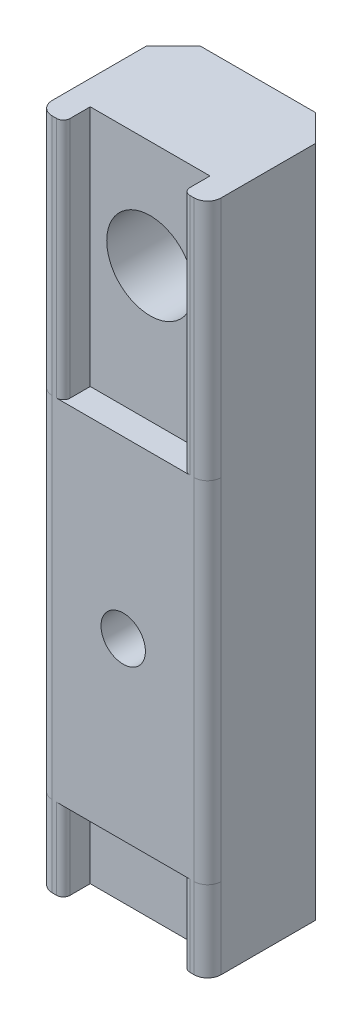
from build123d import *

# Parameters (mm, degrees)
BOSS_EXTRUDE1_DEPTH = 50
CUT_EXTRUDE2_DEPTH  = 53.511927217
FILLET1_R           = 0.5
SKETCH4_R           = 3.225
SKETCH4_R_2         = 1.65
CUT_EXTRUDE3_DEPTH  = 53.511927217
BOSS_EXTRUDE2_REACH = 54.024
SKETCH5_W           = 12.55
SKETCH5_H           = 26
SKETCH5_R           = 1.65
FILLET2_R           = 1
CUT_EXTRUDE4_DEPTH  = 4
BOSS_EXTRUDE3_DEPTH = 18
SKETCH8_R           = 3.225
CUT_EXTRUDE5_DEPTH  = 53.024056935
BOSS_EXTRUDE4_DEPTH = 6


with BuildPart() as part:
    # Sketch1 → Boss-Extrude1 (new body)
    with BuildSketch(Plane(origin=(0, 0, 0), x_dir=(1, 0, 0), z_dir=(0, 1, 0))):
        with BuildLine():
            Line((0, 8), (2, 10))
            Line((2, 10), (10.55, 10))
            Line((10.55, 10), (12.55, 8))
            Line((12.55, 8), (12.55, 1))
            ThreePointArc((12.55, 1), (12.257106781, 0.292893219), (11.55, 0))
            Line((11.55, 0), (1, 0))
            ThreePointArc((1, 0), (0.292893219, 0.292893219), (0, 1))
            Line((0, 1), (0, 8))
        make_face()
    extrude(amount=BOSS_EXTRUDE1_DEPTH)

    # Sketch3 → Cut-Extrude2 (cut, through all)
    with BuildSketch(Plane.XZ):
        Polygon((1.825, 0), (1.825, -2), (2.825, -3), (9.725, -3), (10.725, -2), (10.725, 0), align=None)
    extrude(amount=-CUT_EXTRUDE2_DEPTH, mode=Mode.SUBTRACT)

    # Fillet1
    fillet1_edges = [part.edges().sort_by_distance(p)[0] for p in [
        (1.825, 25, 0),
        (10.725, 25, 0),
    ]]
    fillet(fillet1_edges, radius=FILLET1_R)

    # Sketch4 → Cut-Extrude3 (cut, through all)
    with BuildSketch(Plane(origin=(0, 0, -10), x_dir=(-1, 0, 0), z_dir=(0, 0, -1))):
        with Locations((-6.275, 42)):
            Circle(SKETCH4_R)
        with Locations((-6.275, 19)):
            Circle(SKETCH4_R_2)
    extrude(amount=-CUT_EXTRUDE3_DEPTH, mode=Mode.SUBTRACT)

    # Boss-Extrude2: up to this face of the body (flat: up to its plane)
    boss_extrude2_end = Plane(part.part.faces().sort_by_distance((1.1625, 25, 0))[0])
    # Sketch5 → Boss-Extrude2 (add, up to the picked face)
    with BuildSketch(Plane.XY.offset(-3), mode=Mode.PRIVATE) as boss_extrude2_sk1:
        with Locations((6.275, 19)):
            Rectangle(SKETCH5_W, SKETCH5_H)
        with Locations(Location((6.275, 19, 0), (0, 0, 180))):
            Circle(SKETCH5_R, mode=Mode.SUBTRACT)
    boss_extrude2_tool1 = split(extrude(boss_extrude2_sk1.sketch, amount=BOSS_EXTRUDE2_REACH, mode=Mode.PRIVATE), bisect_by=boss_extrude2_end, keep=Keep.BOTH, mode=Mode.PRIVATE)
    add(boss_extrude2_tool1.solids().sort_by(Axis((6.275, 6.288704, -3), (0, 0, 1)))[0])

    # Fillet2
    fillet2_edges = [part.edges().sort_by_distance(p)[0] for p in [
        (12.55, 19, 0),
        (0, 19, 0),
    ]]
    fillet(fillet2_edges, radius=FILLET2_R)

    # Sketch6 → Cut-Extrude4 (cut)
    with BuildSketch(Plane(origin=(0, 0, -10), x_dir=(-1, 0, 0), z_dir=(0, 0, -1))):
        Polygon((-3.012970979, 19), (-4.64398549, 21.825), (-7.90601451, 21.825), (-9.537029021, 19), (-7.90601451, 16.175), (-4.64398549, 16.175), align=None)
    extrude(amount=-CUT_EXTRUDE4_DEPTH, mode=Mode.SUBTRACT)

    # Sketch7 → Boss-Extrude3 (add)
    with BuildSketch(Plane(origin=(0, 32, 0), x_dir=(1, 0, 0), z_dir=(0, 1, 0))):
        Polygon((1.825, 2), (10.725, 2), (9.725, 3), (2.825, 3), align=None)
    extrude(amount=BOSS_EXTRUDE3_DEPTH)

    # Sketch8 → Cut-Extrude5 (cut, through all)
    with BuildSketch(Plane(origin=(0, 0, -3), x_dir=(-1, 0, 0), z_dir=(0, 0, -1))):
        with Locations((-6.275, 42)):
            Circle(SKETCH8_R)
    extrude(amount=-CUT_EXTRUDE5_DEPTH, mode=Mode.SUBTRACT)

    # Sketch9 → Boss-Extrude4 (add)
    with BuildSketch(Plane.XZ.offset(-6)):
        Polygon((1.825, -2), (10.725, -2), (9.725, -3), (2.825, -3), align=None)
    extrude(amount=BOSS_EXTRUDE4_DEPTH)


solid = part.part
